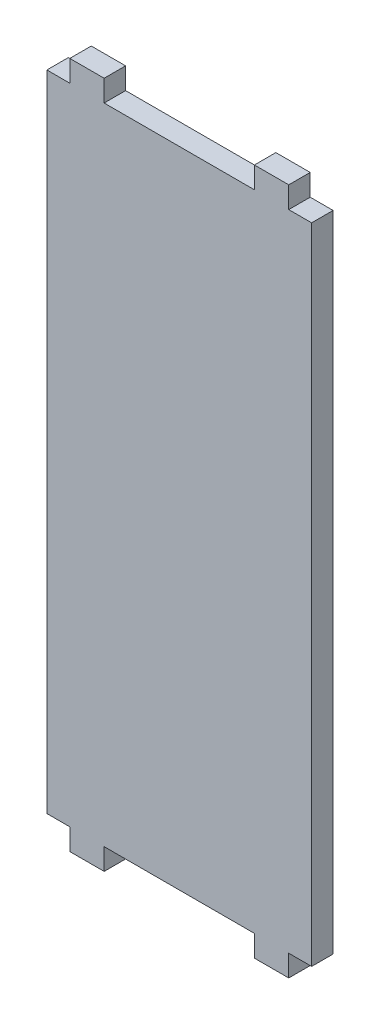
from build123d import *

# Parameters (mm, degrees)
BOSS_EXTRUDE1_DEPTH = 4.7625


with BuildPart() as part:
    # Sketch1 → Boss-Extrude1 (new body)
    with BuildSketch(Plane.XY):
        Polygon((-12.7, -4.7625), (-5.08, -4.7625), (-5.08, 0), (0, 0), (0, 142.875), (-5.08, 142.875), (-5.08, 147.6375), (-12.7, 147.6375), (-12.7, 142.875), (-46.0375, 142.875), (-46.0375, 147.6375), (-53.6575, 147.6375), (-53.6575, 142.875), (-58.7375, 142.875), (-58.7375, 0), (-53.6575, 0), (-53.6575, -4.7625), (-46.0375, -4.7625), (-46.0375, 0), (-12.7, 0), align=None)
    extrude(amount=BOSS_EXTRUDE1_DEPTH)


solid = part.part
